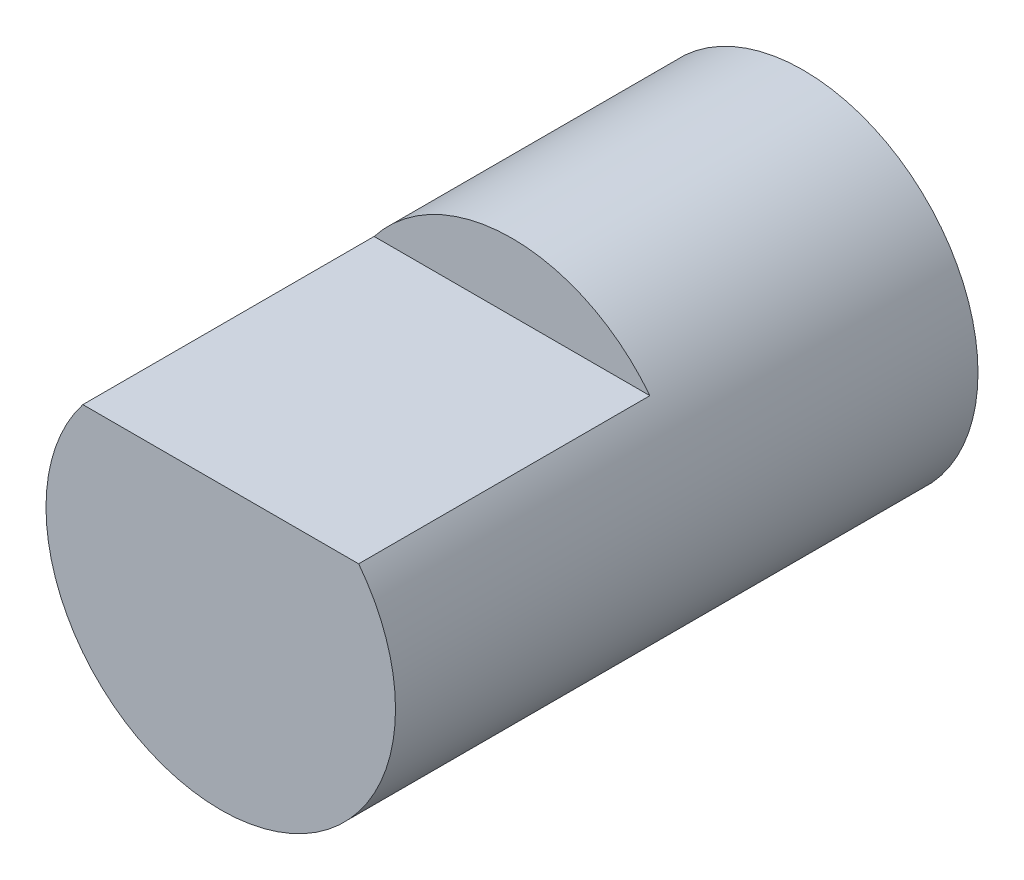
from build123d import *

# Parameters (mm, degrees)
CROQUIS1_R              = 3
SALIENTE_EXTRUIR1_DEPTH = 10
CORTAR_EXTRUIR1_DEPTH   = 5


with BuildPart() as part:
    # Croquis1 → Saliente-Extruir1 (new body)
    with BuildSketch(Plane.XY):
        Circle(CROQUIS1_R)
    extrude(amount=SALIENTE_EXTRUIR1_DEPTH)

    # Croquis2 → Cortar-Extruir1 (cut)
    with BuildSketch(Plane.XY.offset(10)):
        with BuildLine():
            Line((-2.367302512, 1.84279104), (2.367302512, 1.84279104))
            ThreePointArc((2.367302512, 1.84279104), (0, 3), (-2.367302512, 1.84279104))
        make_face()
    extrude(amount=-CORTAR_EXTRUIR1_DEPTH, mode=Mode.SUBTRACT)


solid = part.part
